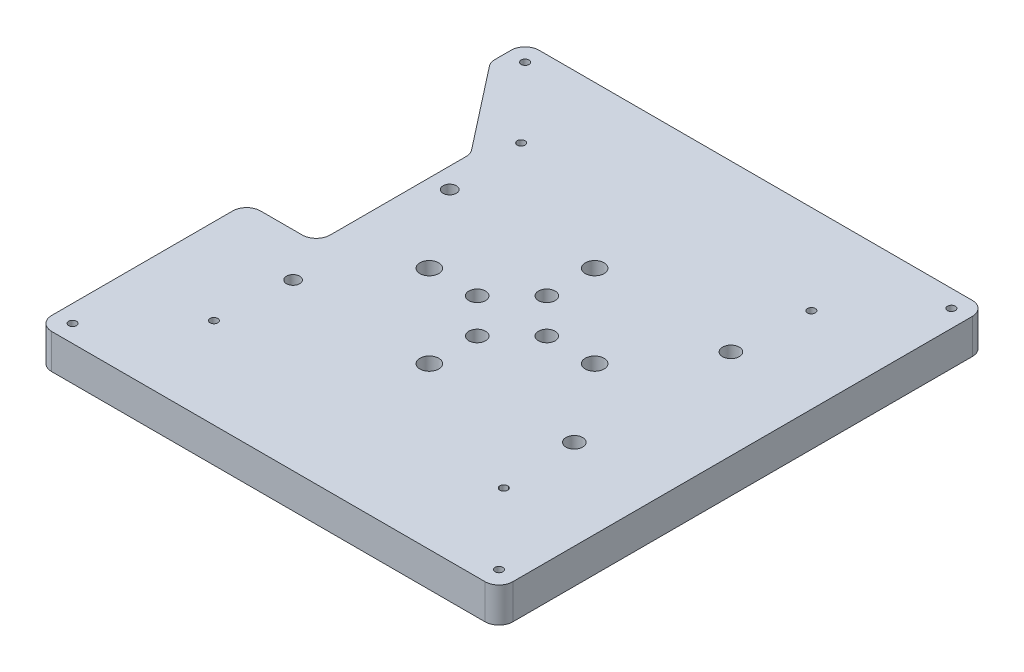
from build123d import *

# Parameters (mm, degrees)
SKETCH2_W               = 168.275
SKETCH2_H               = 177.8
SKETCH2_R               = 3.048
SKETCH2_R_2             = 2.413
SKETCH2_R_3             = 1.4224
SKETCH2_R_4             = 3.429
BOSS_EXTRUDE2_DEPTH     = 12.7
CUT_EXTRUDE1_DEPTH      = 1
CUT_EXTRUDE1_DEPTH_BACK = 13.7
FILLET1_R               = 5.08


with BuildPart() as part:
    # Sketch2 → Boss-Extrude2 (new body)
    with BuildSketch(Plane(origin=(0, 0, 0), x_dir=(1, 0, 0), z_dir=(0, 1, 0))):
        with Locations((84.1375, 88.9)):
            Rectangle(SKETCH2_W, SKETCH2_H)
        with Locations((84.1375, 101.6)):
            Circle(SKETCH2_R, mode=Mode.SUBTRACT)
        with Locations((96.8375, 88.9)):
            Circle(SKETCH2_R, mode=Mode.SUBTRACT)
        with Locations((84.1375, 76.2)):
            Circle(SKETCH2_R, mode=Mode.SUBTRACT)
        with Locations((71.4375, 88.9)):
            Circle(SKETCH2_R, mode=Mode.SUBTRACT)
        with Locations((32.8295, 117.475)):
            Circle(SKETCH2_R_2, mode=Mode.SUBTRACT)
        with Locations((135.4455, 117.475)):
            Circle(SKETCH2_R, mode=Mode.SUBTRACT)
        with Locations((135.4455, 60.325)):
            Circle(SKETCH2_R, mode=Mode.SUBTRACT)
        with Locations((32.8295, 60.325)):
            Circle(SKETCH2_R_2, mode=Mode.SUBTRACT)
        with Locations((6.35, 171.45)):
            Circle(SKETCH2_R_3, mode=Mode.SUBTRACT)
        with Locations((161.925, 171.45)):
            Circle(SKETCH2_R_3, mode=Mode.SUBTRACT)
        with Locations((161.925, 6.35)):
            Circle(SKETCH2_R_3, mode=Mode.SUBTRACT)
        with Locations((6.35, 6.35)):
            Circle(SKETCH2_R_3, mode=Mode.SUBTRACT)
        with Locations((31.251071429, 33.02)):
            Circle(SKETCH2_R_3, mode=Mode.SUBTRACT)
        with Locations((137.023928571, 33.02)):
            Circle(SKETCH2_R_3, mode=Mode.SUBTRACT)
        with Locations((84.1375, 119.0625)):
            Circle(SKETCH2_R_4, mode=Mode.SUBTRACT)
        with Locations((114.3, 88.9)):
            Circle(SKETCH2_R_4, mode=Mode.SUBTRACT)
        with Locations((84.1375, 58.7375)):
            Circle(SKETCH2_R_4, mode=Mode.SUBTRACT)
        with Locations((53.975, 88.9)):
            Circle(SKETCH2_R_4, mode=Mode.SUBTRACT)
        with Locations((31.149471429, 145.2372)):
            Circle(SKETCH2_R_3, mode=Mode.SUBTRACT)
        with Locations((137.125528571, 145.161)):
            Circle(SKETCH2_R_3, mode=Mode.SUBTRACT)
    extrude(amount=BOSS_EXTRUDE2_DEPTH)

    # Sketch3 → Cut-Extrude1 (cut, two sides)
    with BuildSketch(Plane(origin=(0, 12.7, 0), x_dir=(1, 0, 0), z_dir=(0, 1, 0))) as cut_extrude1_sk:
        Polygon((0, 165.1), (0, 76.2), (25.4, 76.2), (25.4, 132.589482542), align=None)
    extrude(amount=CUT_EXTRUDE1_DEPTH, mode=Mode.SUBTRACT)
    extrude(cut_extrude1_sk.sketch, amount=-CUT_EXTRUDE1_DEPTH_BACK, mode=Mode.SUBTRACT)

    # Fillet1
    fillet1_edges = [part.edges().sort_by_distance(p)[0] for p in [
        (0, 6.35, -165.1),
        (25.4, 6.35, -132.589482542),
        (25.4, 6.35, -76.2),
        (0, 6.35, -76.2),
        (0, 6.35, -177.8),
        (168.275, 6.35, -177.8),
        (168.275, 6.35, 0),
        (0, 6.35, 0),
    ]]
    fillet(fillet1_edges, radius=FILLET1_R)


solid = part.part
